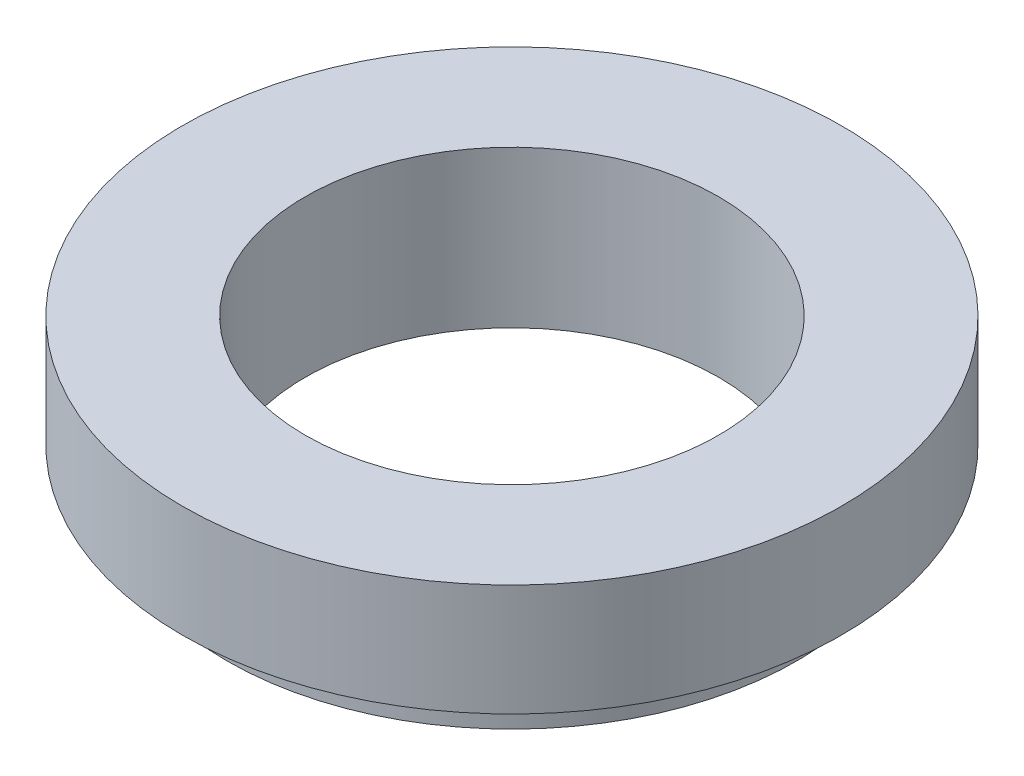
from build123d import *


with BuildPart() as part:
    # Эскиз1 → Повернуть1 (revolve)
    with BuildSketch(Plane.XY):
        Polygon((18.5, 0), (18.5, -14), (25.5, -14), (25.5, -10), (29.5, -10), (29.5, 0), align=None)
    revolve(axis=Axis((0, 0, 0), (0, -1, 0)))


solid = part.part
